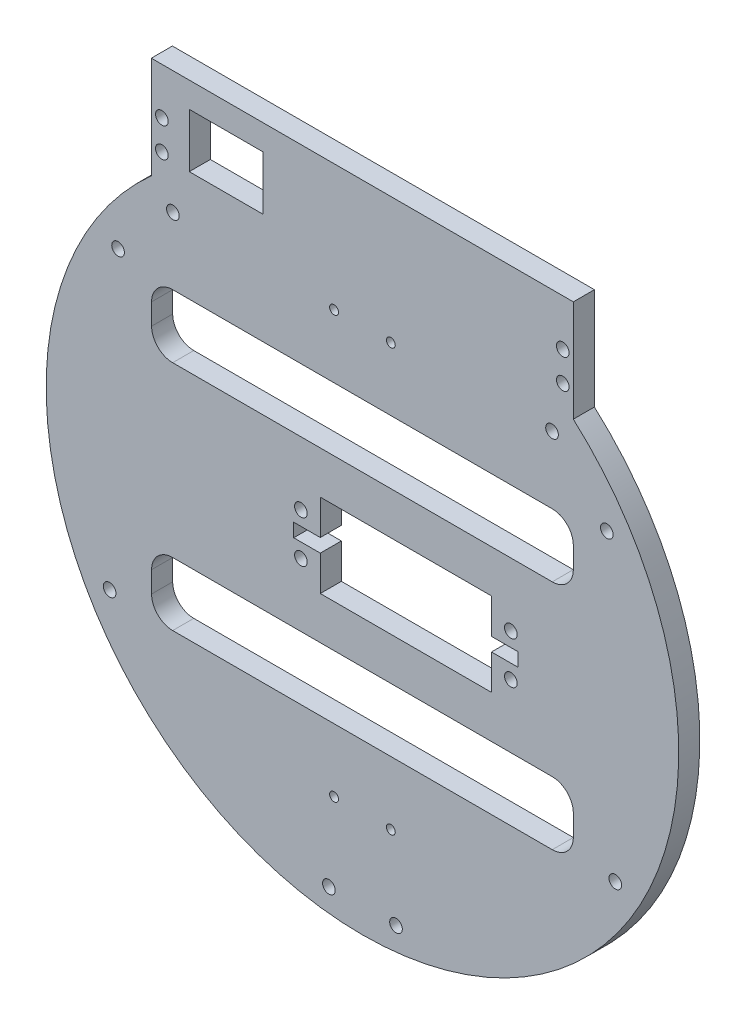
from build123d import *

# Parameters (mm, degrees)
RESSALTO_EXTRUS_O1_DEPTH = 5
ESBO_O2_R                = 1.5
CORTE_EXTRUS_O1_DEPTH    = 10
ESBO_O3_W                = 6.3
ESBO_O3_H                = 3.2
ESBO_O3_R                = 1.5
CORTE_EXTRUS_O2_DEPTH    = 10
ESBO_O4_W                = 17.5
ESBO_O4_H                = 12.8
CORTE_EXTRUS_O3_DEPTH    = 6
ESBO_O5_R                = 1.5
CORTE_EXTRUS_O4_DEPTH    = 10
ESBO_O6_R                = 1.05
CORTE_EXTRUS_O5_DEPTH    = 10
CORTE_EXTRUS_O6_DEPTH    = 6


with BuildPart() as part:
    # Esboço1 → Ressalto-extrusão1 (new body)
    with BuildSketch(Plane.XY):
        with BuildLine():
            Line((44.495405461, -168.430491325), (44.495405461, -144.332190763))
            Line((44.495405461, -144.332190763), (-55.573351401, -144.332190763))
            Line((-55.573351401, -144.332190763), (-55.573351401, -168.393072388))
            Line((-55.573351401, -168.393072388), (-55.504594539, -168.430491325))
            ThreePointArc((-55.504594539, -168.430491325), (-5.504594539, -299.332190763), (44.495405461, -168.430491325))
        make_face()
    extrude(amount=RESSALTO_EXTRUS_O1_DEPTH)

    # Esboço2 → Corte-extrusão1 (cut)
    with BuildSketch(Plane.XY.offset(5)):
        with Locations((39.44625518, -173.430491325)):
            Circle(ESBO_O2_R)
        with Locations((52.44625518, -187.430491325)):
            Circle(ESBO_O2_R)
        with Locations((54.44625518, -258.430491325)):
            Circle(ESBO_O2_R)
        with Locations((-13.455444258, -293.430491325)):
            Circle(ESBO_O2_R)
        with Locations((2.44625518, -293.430491325)):
            Circle(ESBO_O2_R)
        with Locations((-65.455444258, -258.430491325)):
            Circle(ESBO_O2_R)
        with Locations((-63.455444258, -187.430491325)):
            Circle(ESBO_O2_R)
        with Locations((-50.455444258, -173.430491325)):
            Circle(ESBO_O2_R)
    extrude(amount=-CORTE_EXTRUS_O1_DEPTH, mode=Mode.SUBTRACT)

    # Esboço3 → Corte-extrusão2 (cut)
    with BuildSketch(Plane.XY.offset(5)):
        with Locations((28.245405461, -224.332190763)):
            Rectangle(ESBO_O3_W, ESBO_O3_H)
        Polygon((-21.804594539, -225.932190763), (-21.804594539, -222.732190763), (-15.504594539, -222.732190763), (-15.504594539, -214.432190763), (25.095405461, -214.432190763), (25.095405461, -234.232190763), (-15.504594539, -234.232190763), (-15.504594539, -225.932190763), align=None)
        with Locations((29.685405461, -229.332190763)):
            Circle(ESBO_O3_R)
        with Locations((29.685405461, -219.332190763)):
            Circle(ESBO_O3_R)
        with Locations((-20.094594539, -229.332190763)):
            Circle(ESBO_O3_R)
        with Locations((-20.094594539, -219.332190763)):
            Circle(ESBO_O3_R)
    extrude(amount=-CORTE_EXTRUS_O2_DEPTH, mode=Mode.SUBTRACT)

    # Esboço4 → Corte-extrusão3 (cut, through all)
    with BuildSketch(Plane.XY.offset(5)):
        with Locations((-37.823351401, -156.732190763)):
            Rectangle(ESBO_O4_W, ESBO_O4_H)
    extrude(amount=-CORTE_EXTRUS_O3_DEPTH, mode=Mode.SUBTRACT)

    # Esboço5 → Corte-extrusão4 (cut)
    with BuildSketch(Plane(origin=(0, 0, 0), x_dir=(-1, 0, 0), z_dir=(0, 0, -1))):
        with Locations((53.073351401, -155.332190763)):
            Circle(ESBO_O5_R)
        with Locations((53.073351401, -162.332190763)):
            Circle(ESBO_O5_R)
        with Locations((-41.995405461, -155.332190763)):
            Circle(ESBO_O5_R)
        with Locations((-41.995405461, -162.332190763)):
            Circle(ESBO_O5_R)
    extrude(amount=-CORTE_EXTRUS_O4_DEPTH, mode=Mode.SUBTRACT)

    # Esboço6 → Corte-extrusão5 (cut)
    with BuildSketch(Plane(origin=(0, 0, 0), x_dir=(-1, 0, 0), z_dir=(0, 0, -1))):
        with Locations((12.234594539, -174.332190763)):
            Circle(ESBO_O6_R)
        with Locations((-1.225405461, -174.332190763)):
            Circle(ESBO_O6_R)
        with Locations((-1.225405461, -274.332190763)):
            Circle(ESBO_O6_R)
        with Locations((12.234594539, -274.332190763)):
            Circle(ESBO_O6_R)
    extrude(amount=-CORTE_EXTRUS_O5_DEPTH, mode=Mode.SUBTRACT)

    # Esboço7 → Corte-extrusão6 (cut, through all)
    with BuildSketch(Plane(origin=(0, 0, 0), x_dir=(-1, 0, 0), z_dir=(0, 0, -1))):
        with BuildLine():
            Line((55.504594539, -254.332190763), (55.504594539, -249.332190763))
            ThreePointArc((55.504594539, -249.332190763), (54.040128445, -245.796656857), (50.504594539, -244.332190763))
            Line((50.504594539, -244.332190763), (-39.495405461, -244.332190763))
            ThreePointArc((-39.495405461, -244.332190763), (-43.030939367, -245.796656857), (-44.495405461, -249.332190763))
            Line((-44.495405461, -249.332190763), (-44.495405461, -254.332190763))
            ThreePointArc((-44.495405461, -254.332190763), (-43.030939367, -257.867724668), (-39.495405461, -259.332190763))
            Line((-39.495405461, -259.332190763), (50.504594539, -259.332190763))
            ThreePointArc((50.504594539, -259.332190763), (54.040128445, -257.867724668), (55.504594539, -254.332190763))
        make_face()
        with BuildLine():
            ThreePointArc((-39.495405461, -204.332190763), (-43.030939367, -202.867724668), (-44.495405461, -199.332190763))
            Line((-44.495405461, -199.332190763), (-44.495405461, -194.332190763))
            ThreePointArc((-44.495405461, -194.332190763), (-43.030939367, -190.796656857), (-39.495405461, -189.332190763))
            Line((-39.495405461, -189.332190763), (50.504594539, -189.332190763))
            ThreePointArc((50.504594539, -189.332190763), (54.040128445, -190.796656857), (55.504594539, -194.332190763))
            Line((55.504594539, -194.332190763), (55.504594539, -199.332190763))
            ThreePointArc((55.504594539, -199.332190763), (54.040128445, -202.867724668), (50.504594539, -204.332190763))
            Line((50.504594539, -204.332190763), (-39.495405461, -204.332190763))
        make_face()
    extrude(amount=-CORTE_EXTRUS_O6_DEPTH, mode=Mode.SUBTRACT)


solid = part.part
